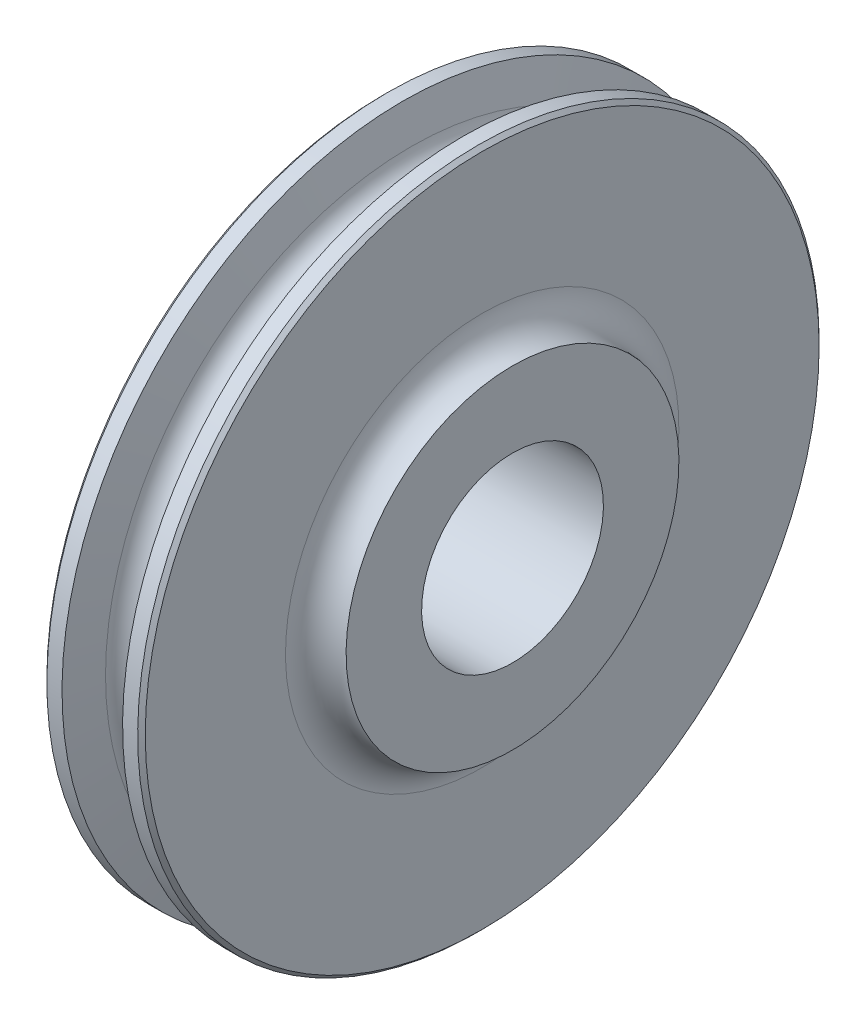
from build123d import *

# Parameters (mm, degrees)
SKETCH2_R          = 19.0627
CUT_EXTRUDE1_DEPTH = 34.3375


with BuildPart() as part:
    # Sketch1 → Revolve1 (revolve)
    with BuildSketch(Plane.XY):
        with BuildLine():
            Line((16.66875, 0), (-16.66875, 0))
            Line((-16.66875, 0), (-16.66875, 34.891972302))
            Line((-16.66875, 34.891972302), (-16.6624, 34.891972302))
            ThreePointArc((-16.6624, 34.891972302), (-12.172271939, 36.751844242), (-10.3124, 41.241972302))
            Line((-10.3124, 41.241972302), (-10.3124, 70.6374))
            Line((-10.3124, 70.6374), (-9.51865, 71.43115))
            Line((-9.51865, 71.43115), (-6.35, 71.43115))
            Line((-6.35, 71.43115), (-4.640755559, 64.017549491))
            ThreePointArc((-4.640755559, 64.017549491), (0, 60.325), (4.640755559, 64.017549491))
            Line((4.640755559, 64.017549491), (6.35, 71.43115))
            Line((6.35, 71.43115), (9.51865, 71.43115))
            Line((9.51865, 71.43115), (10.3124, 70.6374))
            Line((10.3124, 70.6374), (10.3124, 41.241972302))
            ThreePointArc((10.3124, 41.241972302), (12.172271939, 36.751844242), (16.6624, 34.891972302))
            Line((16.6624, 34.891972302), (16.66875, 34.891972302))
            Line((16.66875, 34.891972302), (16.66875, 0))
        make_face()
    revolve(axis=Axis((16.66875, 0, 0), (-1, 0, 0)))

    # Sketch2 → Cut-Extrude1 (cut, through all)
    with BuildSketch(Plane(origin=(16.66875, 0, 0), x_dir=(0, 0, -1), z_dir=(1, 0, 0))):
        with Locations(Location((0, 0, 0), (0, 0, 90))):  # turned: the seam where the file's is
            Circle(SKETCH2_R)
    extrude(amount=-CUT_EXTRUDE1_DEPTH, mode=Mode.SUBTRACT)


solid = part.part
